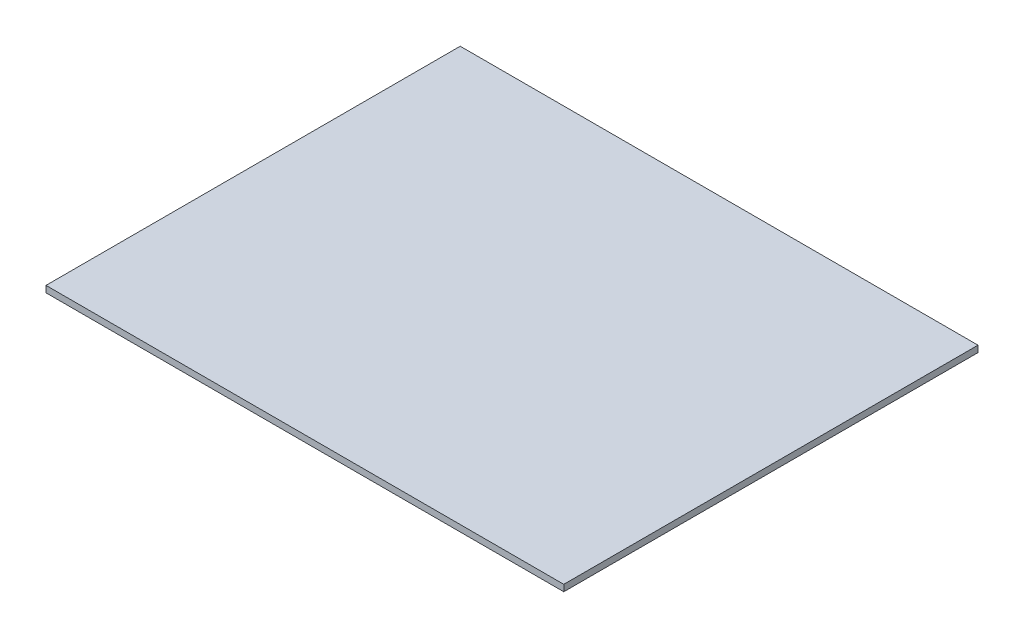
from build123d import *

# Parameters (mm, degrees)
SKETCH_1_W      = 4000
SKETCH_1_H      = 3200
EXTRUDE_1_DEPTH = 50


with BuildPart() as part:
    # 草图1 → 凸台-拉伸1 (new body)
    with BuildSketch(Plane(origin=(0, 0, 0), x_dir=(1, 0, 0), z_dir=(0, 1, 0))):
        with Locations((2000, 1600)):
            Rectangle(SKETCH_1_W, SKETCH_1_H)
    extrude(amount=EXTRUDE_1_DEPTH)


solid = part.part
